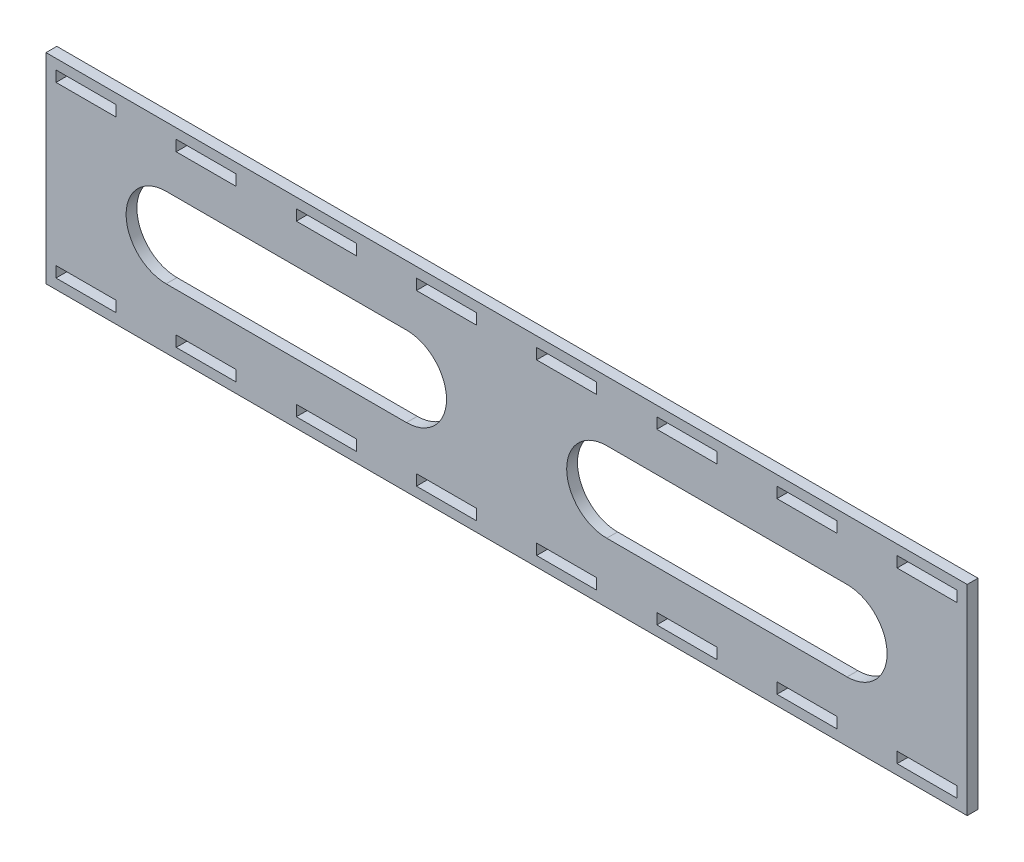
from build123d import *

# Parameters (mm, degrees)
SKETCH1_W           = 460
SKETCH1_H           = 100
SKETCH1_W_2         = 30
SKETCH1_H_2         = 5.4
BOSS_EXTRUDE1_DEPTH = 5.4
CUT_EXTRUDE1_DEPTH  = 6.4


with BuildPart() as part:
    # Sketch1 → Boss-Extrude1 (new body)
    with BuildSketch(Plane.XY):
        with Locations((15.553483591, 15.102805507)):
            Rectangle(SKETCH1_W, SKETCH1_H)
        with Locations((-134.446516409, 57.402805507)):
            Rectangle(SKETCH1_W_2, SKETCH1_H_2, mode=Mode.SUBTRACT)
        with Locations((-194.446516409, 57.402805507)):
            Rectangle(SKETCH1_W_2, SKETCH1_H_2, mode=Mode.SUBTRACT)
        with Locations((-74.446516409, 57.402805507)):
            Rectangle(SKETCH1_W_2, SKETCH1_H_2, mode=Mode.SUBTRACT)
        with Locations((-14.446516409, 57.402805507)):
            Rectangle(SKETCH1_W_2, SKETCH1_H_2, mode=Mode.SUBTRACT)
        with Locations((45.553483591, 57.402805507)):
            Rectangle(SKETCH1_W_2, SKETCH1_H_2, mode=Mode.SUBTRACT)
        with Locations((105.553483591, 57.402805507)):
            Rectangle(SKETCH1_W_2, SKETCH1_H_2, mode=Mode.SUBTRACT)
        with Locations((165.553483591, 57.402805507)):
            Rectangle(SKETCH1_W_2, SKETCH1_H_2, mode=Mode.SUBTRACT)
        with Locations((225.553483591, 57.402805507)):
            Rectangle(SKETCH1_W_2, SKETCH1_H_2, mode=Mode.SUBTRACT)
        with Locations((225.553483591, -27.197194493)):
            Rectangle(SKETCH1_W_2, SKETCH1_H_2, mode=Mode.SUBTRACT)
        with Locations((165.553483591, -27.197194493)):
            Rectangle(SKETCH1_W_2, SKETCH1_H_2, mode=Mode.SUBTRACT)
        with Locations((105.553483591, -27.197194493)):
            Rectangle(SKETCH1_W_2, SKETCH1_H_2, mode=Mode.SUBTRACT)
        with Locations((45.553483591, -27.197194493)):
            Rectangle(SKETCH1_W_2, SKETCH1_H_2, mode=Mode.SUBTRACT)
        with Locations((-14.446516409, -27.197194493)):
            Rectangle(SKETCH1_W_2, SKETCH1_H_2, mode=Mode.SUBTRACT)
        with Locations((-74.446516409, -27.197194493)):
            Rectangle(SKETCH1_W_2, SKETCH1_H_2, mode=Mode.SUBTRACT)
        with Locations((-134.446516409, -27.197194493)):
            Rectangle(SKETCH1_W_2, SKETCH1_H_2, mode=Mode.SUBTRACT)
        with Locations((-194.446516409, -27.197194493)):
            Rectangle(SKETCH1_W_2, SKETCH1_H_2, mode=Mode.SUBTRACT)
    extrude(amount=BOSS_EXTRUDE1_DEPTH)

    # Sketch2 → Cut-Extrude1 (cut, through all)
    with BuildSketch(Plane.XY.offset(5.4)):
        with BuildLine():
            Line((-154.446516409, 35.102805507), (-34.446516409, 35.102805507))
            ThreePointArc((-34.446516409, 35.102805507), (-14.446516409, 15.102805507), (-34.446516409, -4.897194493))
            Line((-34.446516409, -4.897194493), (-154.446516409, -4.897194493))
            ThreePointArc((-154.446516409, -4.897194493), (-174.446516409, 15.102805507), (-154.446516409, 35.102805507))
        make_face()
        with BuildLine():
            Line((65.553483591, -4.897194493), (185.553483591, -4.897194493))
            ThreePointArc((185.553483591, -4.897194493), (205.553483591, 15.102805507), (185.553483591, 35.102805507))
            Line((185.553483591, 35.102805507), (65.553483591, 35.102805507))
            ThreePointArc((65.553483591, 35.102805507), (45.553483591, 15.102805507), (65.553483591, -4.897194493))
        make_face()
    extrude(amount=-CUT_EXTRUDE1_DEPTH, mode=Mode.SUBTRACT)


solid = part.part
